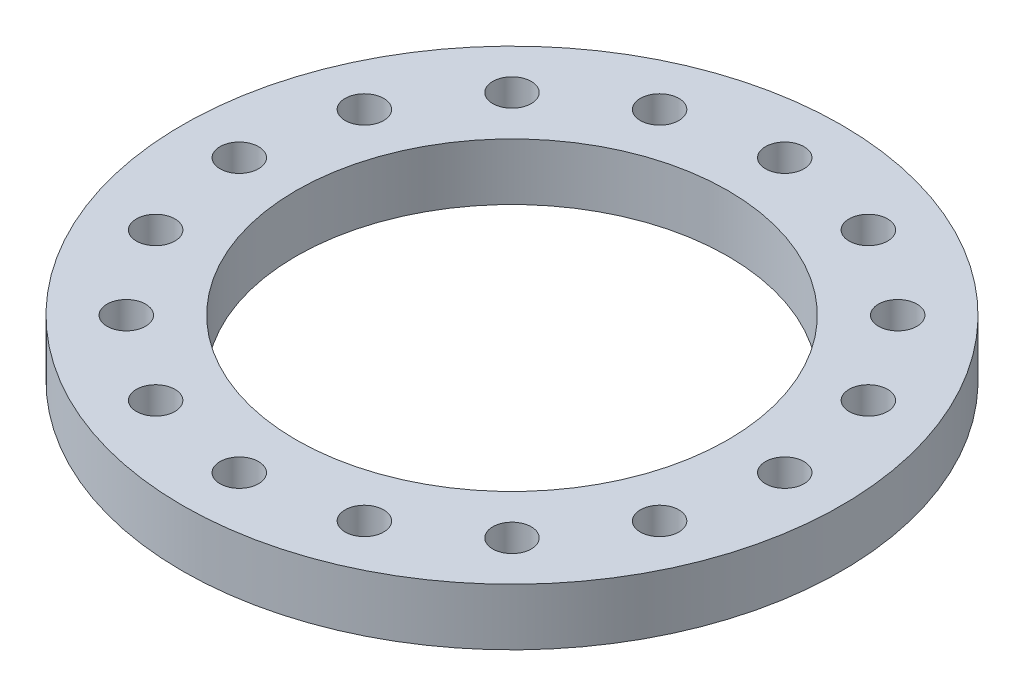
from build123d import *

# Parameters (mm, degrees)
SKETCH1_R           = 36.83
SKETCH1_R_2         = 24.13
SKETCH1_R_3         = 2.15265
BOSS_EXTRUDE1_DEPTH = 6.35


with BuildPart() as part:
    # Sketch1 → Boss-Extrude1 (new body)
    with BuildSketch(Plane(origin=(0, 0, 0), x_dir=(1, 0, 0), z_dir=(0, 1, 0))):
        Circle(SKETCH1_R)
        Circle(SKETCH1_R_2, mode=Mode.SUBTRACT)
        with Locations((0, 30.48)):
            Circle(SKETCH1_R_3, mode=Mode.SUBTRACT)
        with Locations((11.664191018, 28.159848151)):
            Circle(SKETCH1_R_3, mode=Mode.SUBTRACT)
        with Locations((21.552614691, 21.552614691)):
            Circle(SKETCH1_R_3, mode=Mode.SUBTRACT)
        with Locations((28.159848151, 11.664191018)):
            Circle(SKETCH1_R_3, mode=Mode.SUBTRACT)
        with Locations((30.48, 0)):
            Circle(SKETCH1_R_3, mode=Mode.SUBTRACT)
        with Locations((28.159848151, -11.664191018)):
            Circle(SKETCH1_R_3, mode=Mode.SUBTRACT)
        with Locations((21.552614691, -21.552614691)):
            Circle(SKETCH1_R_3, mode=Mode.SUBTRACT)
        with Locations((11.664191018, -28.159848151)):
            Circle(SKETCH1_R_3, mode=Mode.SUBTRACT)
        with Locations((0, -30.48)):
            Circle(SKETCH1_R_3, mode=Mode.SUBTRACT)
        with Locations((-11.664191018, -28.159848151)):
            Circle(SKETCH1_R_3, mode=Mode.SUBTRACT)
        with Locations((-21.552614691, -21.552614691)):
            Circle(SKETCH1_R_3, mode=Mode.SUBTRACT)
        with Locations((-28.159848151, -11.664191018)):
            Circle(SKETCH1_R_3, mode=Mode.SUBTRACT)
        with Locations((-30.48, 0)):
            Circle(SKETCH1_R_3, mode=Mode.SUBTRACT)
        with Locations((-28.159848151, 11.664191018)):
            Circle(SKETCH1_R_3, mode=Mode.SUBTRACT)
        with Locations((-21.552614691, 21.552614691)):
            Circle(SKETCH1_R_3, mode=Mode.SUBTRACT)
        with Locations((-11.664191018, 28.159848151)):
            Circle(SKETCH1_R_3, mode=Mode.SUBTRACT)
    extrude(amount=BOSS_EXTRUDE1_DEPTH)


solid = part.part
